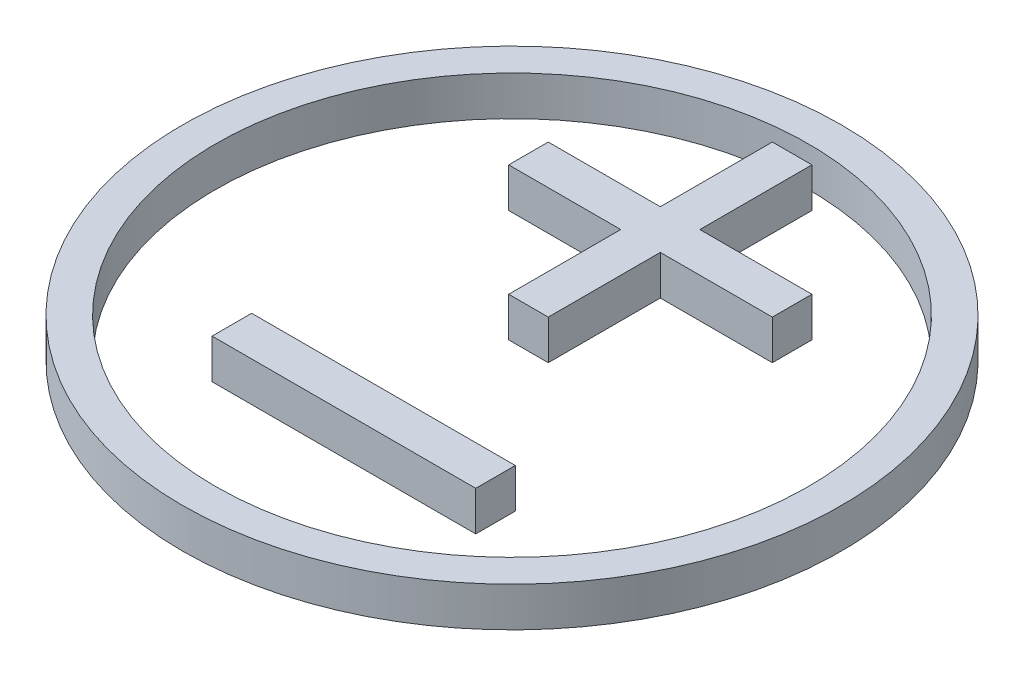
from build123d import *

# Parameters (mm, degrees)
SKETCH1_R           = 50
SKETCH1_R_2         = 45
BOSS_EXTRUDE2_DEPTH = 6


with BuildPart() as part:
    # Sketch1 → Boss-Extrude2 (new body)
    with BuildSketch(Plane(origin=(0, 0, 0), x_dir=(1, 0, 0), z_dir=(0, 1, 0))):
        Circle(SKETCH1_R)
        Circle(SKETCH1_R_2, mode=Mode.SUBTRACT)
        Polygon((0, -19.5), (20, -19.5), (20, -25.5), (0, -25.5), (-20, -25.5), (-20, -19.5), align=None)
        Polygon((20, 25.5), (20, 19.5), (0, 19.5), (-20, 19.5), (-20, 25.5), (0, 25.5), align=None)
        Polygon((-3, 2.5), (3, 2.5), (3, 22.5), (3, 42.5), (-3, 42.5), (-3, 22.5), align=None)
    extrude(amount=BOSS_EXTRUDE2_DEPTH)


solid = part.part
